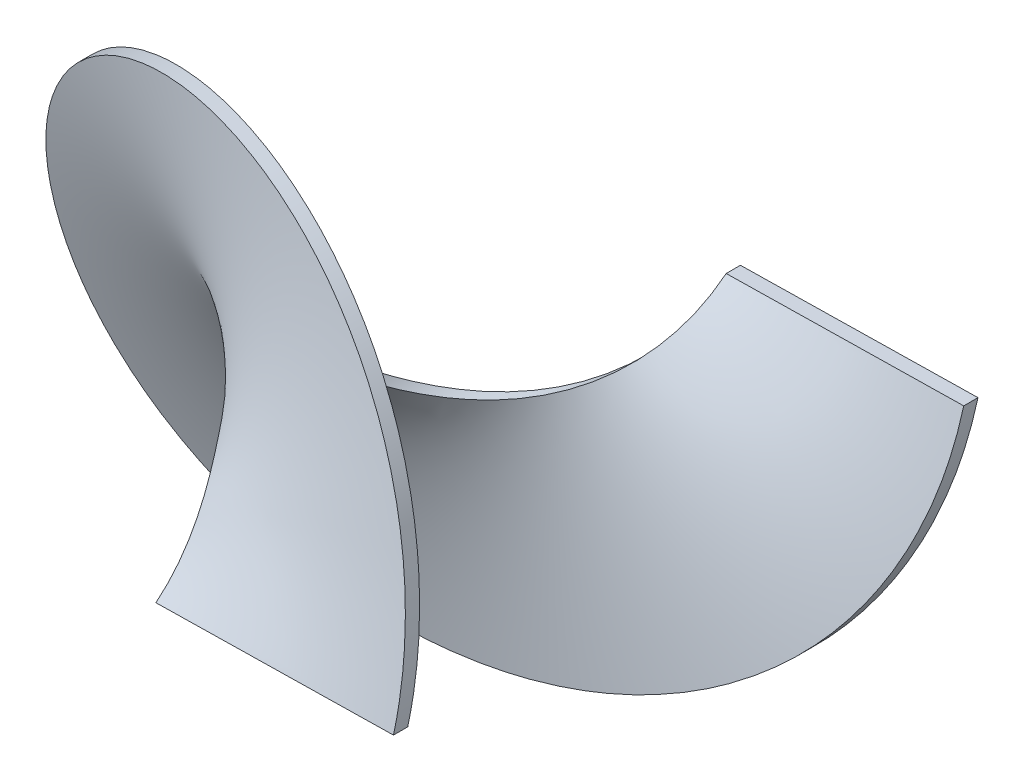
from build123d import *

# Parameters (mm, degrees)
T_HNOUT_PO_K_IVCE1_PITCH       = 120
T_HNOUT_PO_K_IVCE1_HEIGHT      = 120
T_HNOUT_PO_K_IVCE1_RADIUS      = 15
T_HNOUT_PO_K_IVCE1_START_ANGLE = 1
SKICA2_W                       = 50
SKICA2_H                       = 3


with BuildPart() as part:
    # Táhnout po křivce1: sweep along a helix
    with BuildLine() as t_hnout_po_k_ivce1_path:
        add(Helix(T_HNOUT_PO_K_IVCE1_PITCH, T_HNOUT_PO_K_IVCE1_HEIGHT, T_HNOUT_PO_K_IVCE1_RADIUS, center=(0, 0, 0), direction=(0, 0, 1), lefthand=True, mode=Mode.PRIVATE).rotate(Axis((0, 0, 0), (0, 0, 1)), T_HNOUT_PO_K_IVCE1_START_ANGLE))
    # Skica2 → Táhnout po křivce1 (sweep)
    with BuildSketch(Plane(origin=(0, 0, 0), x_dir=(1, 0, 0), z_dir=(0, 1, 0))):
        with Locations((39.997715427, 1.5)):
            Rectangle(SKICA2_W, SKICA2_H)
    sweep(path=t_hnout_po_k_ivce1_path.line, is_frenet=True)


solid = part.part
